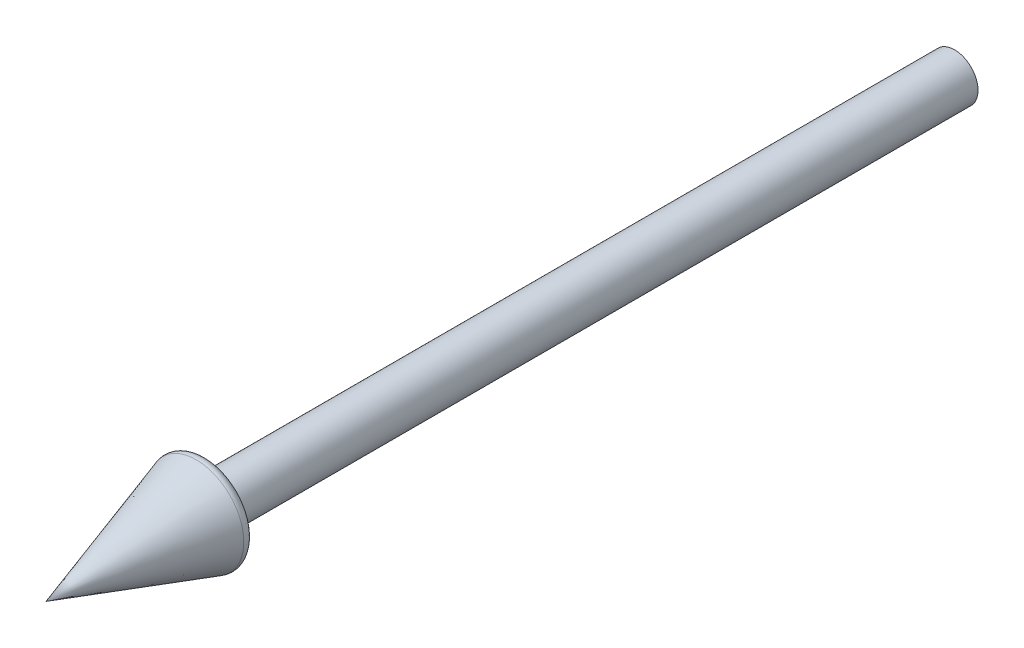
from build123d import *


with BuildPart() as part:
    # Sketch1 → Revolve1 (revolve)
    with BuildSketch(Plane(origin=(0, 0, 0), x_dir=(1, 0, 0), z_dir=(0, 1, 0)), mode=Mode.PRIVATE) as revolve1_sk:
        with BuildLine():
            Line((0, 0), (0, -1219.180903317))
            Line((0, -1219.180903317), (63.717572289, -1017.479558178))
            ThreePointArc((63.717572289, -1017.479558178), (62.248113725, -1008.556391613), (54.182049919, -1004.467281112))
            Line((54.182049919, -1004.467281112), (31.455881238, -1004.467281112))
            Line((31.455881238, -1004.467281112), (31.455881238, 0))
            Line((31.455881238, 0), (0, 0))
        make_face()
    revolve(revolve1_sk.sketch.rotate(Axis((0, 0, 0), (0, 0, 1)), 180), axis=Axis((0, 0, 0), (0, 0, 1)))  # turned: the seam where the file's is


solid = part.part
